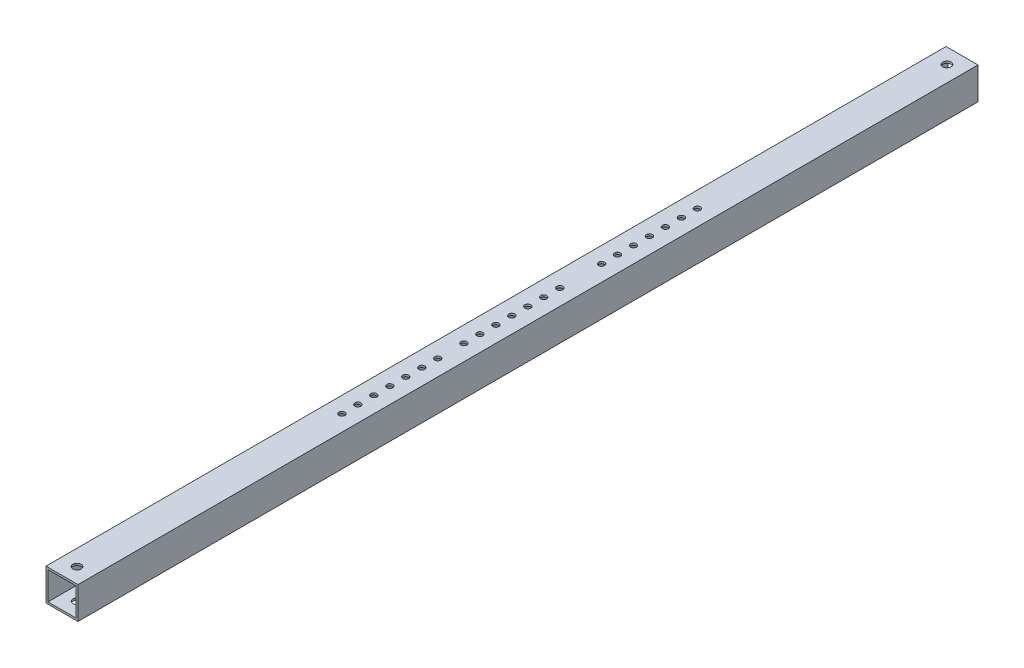
from build123d import *

# Parameters (mm, degrees)
SKETCH1_W            = 25.4
SKETCH1_H            = 25.4
SKETCH1_W_2          = 22.225
SKETCH1_H_2          = 22.225
BOSS_EXTRUDE1_DEPTH  = 357.759
SKETCH2_R            = 2.38125
CUT_EXTRUDE1_DEPTH   = 26.4
SKETCH3_R            = 2.38125
CUT_EXTRUDE2_DEPTH   = 26.4
M6_CLEARANCE_HOLE1_D = 6.6


with BuildPart() as part:
    # Sketch1 → Boss-Extrude1 (new body, symmetric)
    with BuildSketch(Plane.XY):
        Rectangle(SKETCH1_W, SKETCH1_H)
        Rectangle(SKETCH1_W_2, SKETCH1_H_2, mode=Mode.SUBTRACT)
    extrude(amount=BOSS_EXTRUDE1_DEPTH, both=True)

    # Sketch2 → Cut-Extrude1 (cut, through all)
    with BuildSketch(Plane.XZ.offset(12.7)):
        with Locations((0, -37.973)):
            Circle(SKETCH2_R)
        with Locations((0, -25.273)):
            Circle(SKETCH2_R)
        with Locations((0, -12.573)):
            Circle(SKETCH2_R)
        with Locations((0, 0.127)):
            Circle(SKETCH2_R)
        with Locations((0, 12.827)):
            Circle(SKETCH2_R)
        with Locations((0, 25.527)):
            Circle(SKETCH2_R)
        with Locations((0, 38.227)):
            Circle(SKETCH2_R)
    extrude(amount=-CUT_EXTRUDE1_DEPTH, mode=Mode.SUBTRACT)

    # Sketch3 → Cut-Extrude2 (cut, through all)
    with BuildSketch(Plane.XZ.offset(12.7)):
        with Locations((0, 59.018644472)):
            Circle(SKETCH3_R)
        with Locations((0, 71.718644472)):
            Circle(SKETCH3_R)
        with Locations((0, 84.418644472)):
            Circle(SKETCH3_R)
        with Locations((0, 109.818644472)):
            Circle(SKETCH3_R)
        with Locations((0, 122.518644472)):
            Circle(SKETCH3_R)
        with Locations((0, 135.218644472)):
            Circle(SKETCH3_R)
        with Locations((0, 97.118644472)):
            Circle(SKETCH3_R)
        with Locations((0, -71.18135497)):
            Circle(SKETCH3_R)
        with Locations((0, -83.88135497)):
            Circle(SKETCH3_R)
        with Locations((0, -96.58135497)):
            Circle(SKETCH3_R)
        with Locations((0, -109.28135497)):
            Circle(SKETCH3_R)
        with Locations((0, -121.98135497)):
            Circle(SKETCH3_R)
        with Locations((0, -134.68135497)):
            Circle(SKETCH3_R)
        with Locations((0, -147.38135497)):
            Circle(SKETCH3_R)
    extrude(amount=-CUT_EXTRUDE2_DEPTH, mode=Mode.SUBTRACT)

    # M6 Clearance Hole1 (through all)
    with Locations(Plane(origin=(0, -12.7, 0), x_dir=(-1, 0, 0), z_dir=(0, -1, 0))):
        with Locations((0, -345.759), (0, 345.759)):
            Hole(M6_CLEARANCE_HOLE1_D / 2)


solid = part.part
